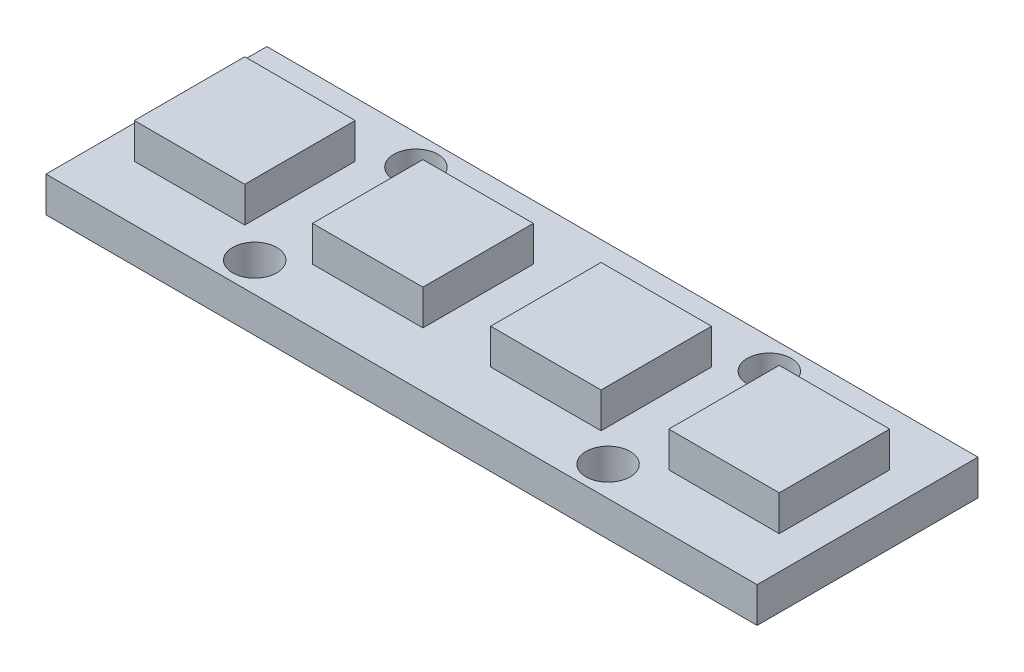
from build123d import *

# Parameters (mm, degrees)
SKETCH1_W           = 32.2
SKETCH1_H           = 10
SKETCH1_R           = 1
PCB_DEPTH           = 1.6
SKETCH2_W           = 5
SKETCH2_H           = 5
BOSS_EXTRUDE2_DEPTH = 1.6


with BuildPart() as part:
    # Sketch1 → PCB (new body)
    with BuildSketch(Plane(origin=(0, 0, 0), x_dir=(1, 0, 0), z_dir=(0, 1, 0))):
        Rectangle(SKETCH1_W, SKETCH1_H)
        with Locations((-8, 3.65)):
            Circle(SKETCH1_R, mode=Mode.SUBTRACT)
        with Locations((8, 3.65)):
            Circle(SKETCH1_R, mode=Mode.SUBTRACT)
        with Locations((8, -3.65)):
            Circle(SKETCH1_R, mode=Mode.SUBTRACT)
        with Locations((-8, -3.65)):
            Circle(SKETCH1_R, mode=Mode.SUBTRACT)
    extrude(amount=PCB_DEPTH)

    # Sketch2 → Boss-Extrude2 (add)
    with BuildSketch(Plane(origin=(0, 1.6, 0), x_dir=(1, 0, 0), z_dir=(0, 1, 0))):
        with Locations((-12.1, 0)):
            Rectangle(SKETCH2_W, SKETCH2_H)
        with Locations((-4.033333333, 0)):
            Rectangle(SKETCH2_W, SKETCH2_H)
        with Locations((4.033333333, 0)):
            Rectangle(SKETCH2_W, SKETCH2_H)
        with Locations((12.1, 0)):
            Rectangle(SKETCH2_W, SKETCH2_H)
    extrude(amount=BOSS_EXTRUDE2_DEPTH)


solid = part.part
